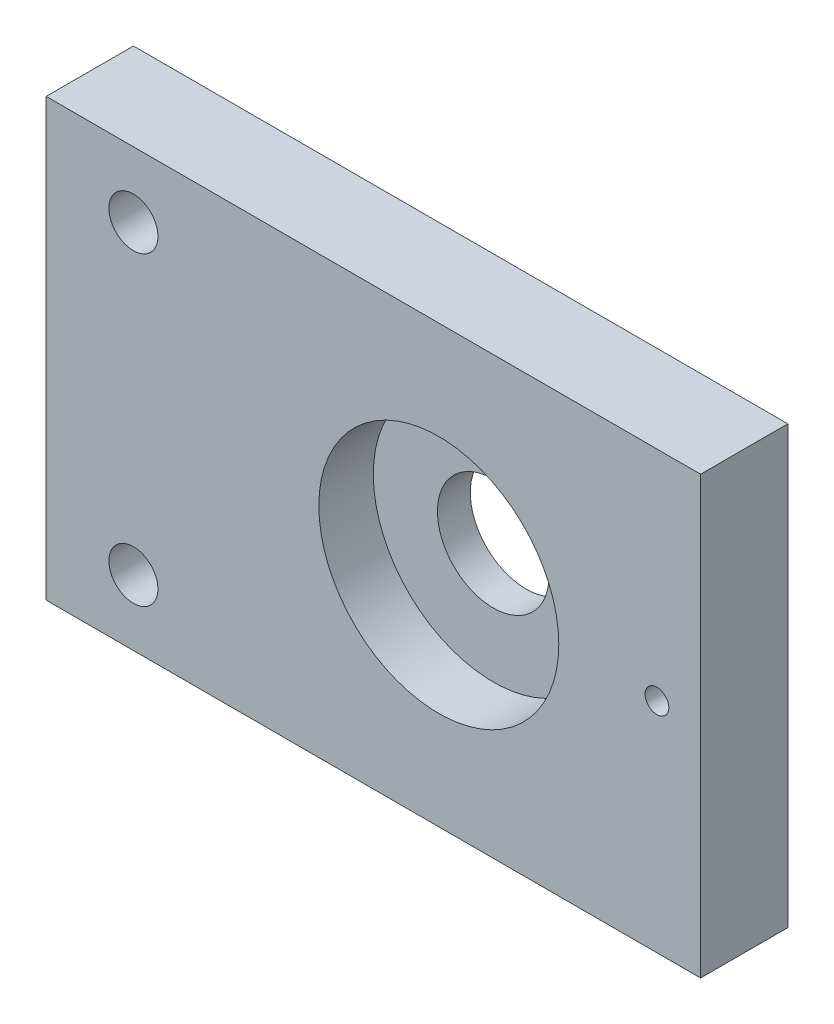
from build123d import *

# Parameters (mm, degrees)
SKETCH1_W                                        = 95.25
SKETCH1_H                                        = 63.5
BOSS_EXTRUDE1_DEPTH                              = 12.7
CBORE_FOR_1_4_SOCKET_HEAD_CAP_SCREW1_D           = 7.14248
CBORE_FOR_1_4_SOCKET_HEAD_CAP_SCREW1_CBORE_D     = 11.1125
CBORE_FOR_1_4_SOCKET_HEAD_CAP_SCREW1_CBORE_DEPTH = 6.35
CBORE_FOR_5_8_SOCKET_HEAD_CAP_SCREW1_D           = 16.256
CBORE_FOR_5_8_SOCKET_HEAD_CAP_SCREW1_CBORE_D     = 34.925
CBORE_FOR_5_8_SOCKET_HEAD_CAP_SCREW1_CBORE_DEPTH = 7.9248
F_8_32_TAPPED_HOLE1_D                            = 3.4544


with BuildPart() as part:
    # Sketch1 → Boss-Extrude1 (new body)
    with BuildSketch(Plane.XY):
        with Locations((47.625, 31.75)):
            Rectangle(SKETCH1_W, SKETCH1_H)
    extrude(amount=BOSS_EXTRUDE1_DEPTH)

    # CBORE for 1/4 Socket Head Cap Screw1 (through all)
    with Locations(Plane(origin=(0, 0, 0), x_dir=(-1, 0, 0), z_dir=(0, 0, -1))):
        with Locations((-12.7, 53.975), (-12.7, 9.525)):
            CounterBoreHole(CBORE_FOR_1_4_SOCKET_HEAD_CAP_SCREW1_D / 2, CBORE_FOR_1_4_SOCKET_HEAD_CAP_SCREW1_CBORE_D / 2, CBORE_FOR_1_4_SOCKET_HEAD_CAP_SCREW1_CBORE_DEPTH)

    # CBORE for 5/8 Socket Head Cap Screw1 (through all)
    with Locations(Plane.XY.offset(12.7)):
        with Locations((57.15, 31.75)):
            CounterBoreHole(CBORE_FOR_5_8_SOCKET_HEAD_CAP_SCREW1_D / 2, CBORE_FOR_5_8_SOCKET_HEAD_CAP_SCREW1_CBORE_D / 2, CBORE_FOR_5_8_SOCKET_HEAD_CAP_SCREW1_CBORE_DEPTH)

    # #8-32 Tapped Hole1 (through all)
    with Locations(Plane.XY.offset(12.7)):
        with Locations((88.9, 31.75)):
            Hole(F_8_32_TAPPED_HOLE1_D / 2)


solid = part.part
